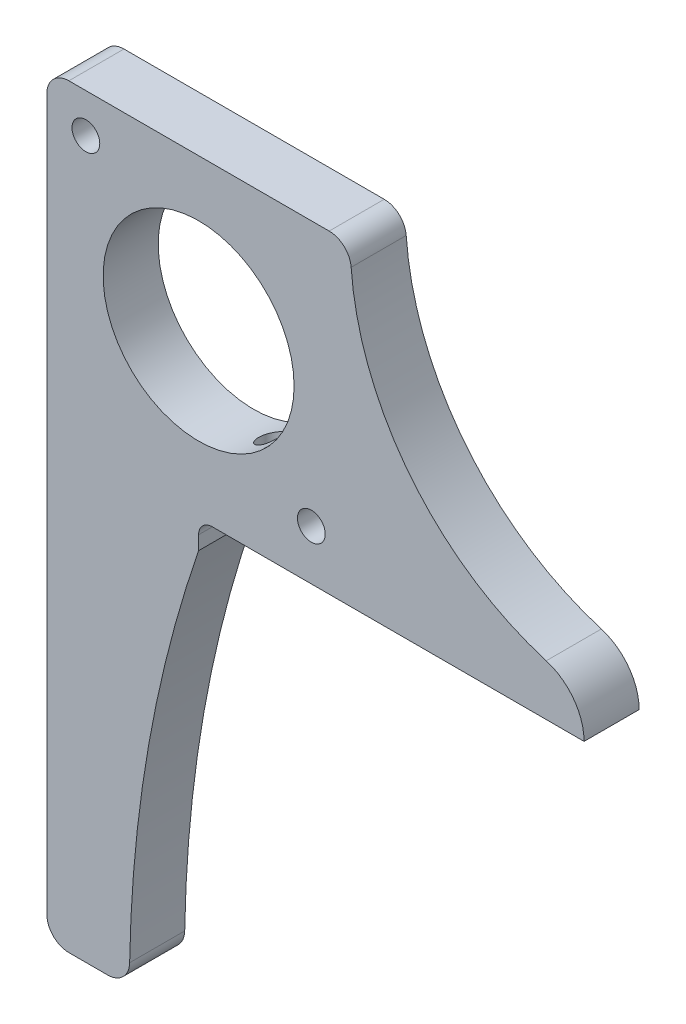
from build123d import *

# Parameters (mm, degrees)
SKETCH1_R                 = 1.6002
SKETCH1_R_2               = 11.0109
BOSS_EXTRUDE1_DEPTH       = 6.35
FILLET1_R                 = 2.54
F_6_32_TAPPED_HOLE1_D     = 2.7051
F_6_32_TAPPED_HOLE1_DEPTH = 9.38784
F_6_32_TAPPED_HOLE1_TIP   = 0.81269403
FILLET2_R                 = 1.5875


with BuildPart() as part:
    # Sketch1 → Boss-Extrude1 (new body)
    with BuildSketch(Plane.XY):
        with BuildLine():
            Line((0, 0), (35, 0))
            ThreePointArc((35, 0), (41.265093292, -18.936262305), (57.587844415, -30.399299417))
            ThreePointArc((57.587844415, -30.399299417), (60.74008766, -32.613036613), (61.95, -36.270000104))
            Line((61.95, -36.270000104), (17.5, -36.270000104))
            Line((17.5, -36.270000104), (17.5, -39.445000104))
            ThreePointArc((17.5, -39.445000104), (11.532534029, -62.925946747), (9.525, -87.070000104))
            Line((9.525, -87.070000104), (0, -87.070000104))
            Line((0, -87.070000104), (0, -36.270000104))
            Line((0, -36.270000104), (0, 0))
        make_face()
        with Locations((4.5, -4.5)):
            Circle(SKETCH1_R, mode=Mode.SUBTRACT)
        with Locations((17.5, -17.5)):
            Circle(SKETCH1_R_2, mode=Mode.SUBTRACT)
        with Locations((30.5, -30.5)):
            Circle(SKETCH1_R, mode=Mode.SUBTRACT)
    extrude(amount=BOSS_EXTRUDE1_DEPTH)

    # Fillet1
    fillet1_edges = [part.edges().sort_by_distance(p)[0] for p in [
        (0, 0, 3.175),
        (35, 0, 3.175),
        (9.525, -87.070000104, 3.175),
        (0, -87.070000104, 3.175),
    ]]
    fillet(fillet1_edges, radius=FILLET1_R)

    # #6-32 Tapped Hole1
    with Locations(Plane(origin=(0, -36.270000104, 0), x_dir=(-1, 0, 0), z_dir=(0, -1, 0))):
        with Locations((-22.58, -3.175), (-47.98, -3.175)):
            Hole(F_6_32_TAPPED_HOLE1_D / 2, depth=F_6_32_TAPPED_HOLE1_DEPTH)
            with Locations((0, 0, -(F_6_32_TAPPED_HOLE1_DEPTH + F_6_32_TAPPED_HOLE1_TIP / 2))):  # 118° drill point
                Cone(0, F_6_32_TAPPED_HOLE1_D / 2, F_6_32_TAPPED_HOLE1_TIP, mode=Mode.SUBTRACT)

    # Fillet2
    fillet2_edges = [part.edges().sort_by_distance(p)[0] for p in [
        (17.5, -36.270000104, 3.175),
    ]]
    fillet(fillet2_edges, radius=FILLET2_R)


solid = part.part
